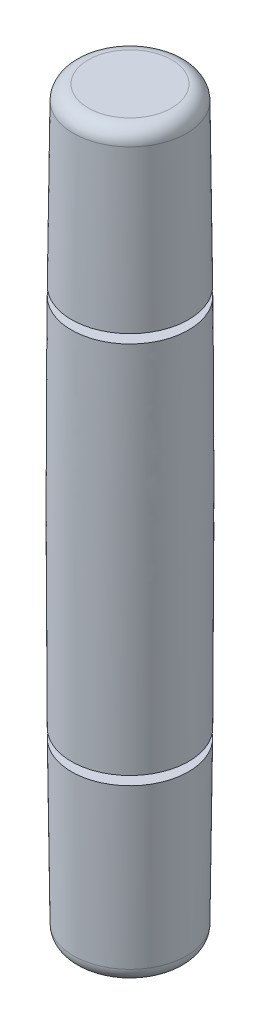
from build123d import *

# Parameters (mm, degrees)
CONG_1_R    = 0.5
ESQUISSE2_W = 0.5
ESQUISSE2_H = 0.3


with BuildPart() as part:
    # Esquisse1 → Révolution1 (revolve)
    with BuildSketch(Plane.XY):
        with BuildLine():
            Line((0, 25), (1.9, 25))
            add(Edge.make_bspline(
                [(1.9, 25), (2.1, 12.5), (1.9, 0)],
                knots=[0, 0, 0, 1, 1, 1], degree=2))
            Line((1.9, 0), (0, 0))
            Line((0, 0), (0, 25))
        make_face()
    revolve(axis=Axis((0, 0, 0), (0, 1, 0)))

    # Congé1
    cong_1_edges = [part.edges().sort_by_distance(p)[0] for p in [
        (-1.9, 25, 0),
        (-1.9, 0, 0),
    ]]
    fillet(cong_1_edges, radius=CONG_1_R)

    # Esquisse2 → Enlèvement de matière-Révolution1 (revolve, cut)
    with BuildSketch(Plane.XY):
        with Locations((1.724599487, 6.05)):
            Rectangle(ESQUISSE2_W, ESQUISSE2_H)
        with Locations((1.724599487, 18.95)):
            Rectangle(ESQUISSE2_W, ESQUISSE2_H)
    revolve(axis=Axis((0, 0, 0), (0, 1, 0)), mode=Mode.SUBTRACT)


solid = part.part
